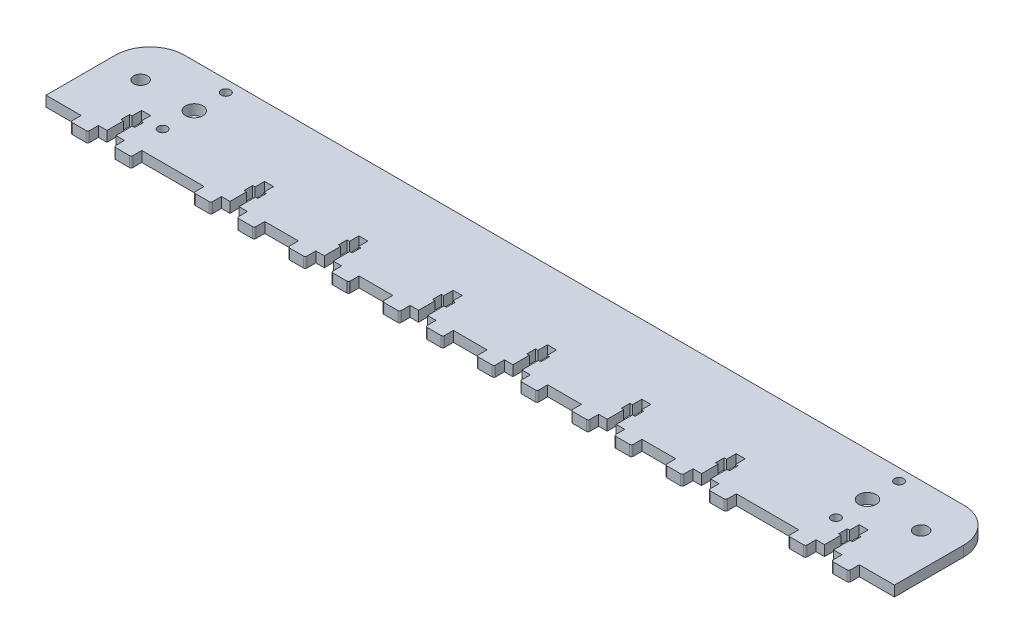
from build123d import *

# Parameters (mm, degrees)
SKETCH2_W                  = 490
SKETCH2_H                  = 60
BOSS_EXTRUDE1_DEPTH        = 6
F_10_0_10_DIAMETER_HOLE1_D = 10
M5_CLEARANCE_HOLE1_D       = 5.3
F_8_0_8_DIAMETER_HOLE1_D   = 8
CUT_EXTRUDE2_DEPTH         = 4
CUT_EXTRUDE2_DEPTH_BACK    = 4
SKETCH234_W                = 6.1
SKETCH234_H                = 10
BOSS_EXTRUDE2_DEPTH        = 3
BOSS_EXTRUDE2_DEPTH_BACK   = 3
FILLET1_R                  = 1
CUT_EXTRUDE21_DEPTH        = 4
CUT_EXTRUDE21_DEPTH_BACK   = 4
SKETCH2341_W               = 6.1
SKETCH2341_H               = 10
BOSS_EXTRUDE21_DEPTH       = 3
BOSS_EXTRUDE21_DEPTH_BACK  = 3
FILLET11_R                 = 1
CUT_EXTRUDE22_DEPTH        = 4
CUT_EXTRUDE22_DEPTH_BACK   = 4
SKETCH2342_W               = 6.1
SKETCH2342_H               = 10
BOSS_EXTRUDE22_DEPTH       = 3
BOSS_EXTRUDE22_DEPTH_BACK  = 3
FILLET12_R                 = 1
CUT_EXTRUDE23_DEPTH        = 4
CUT_EXTRUDE23_DEPTH_BACK   = 4
SKETCH2343_W               = 6.1
SKETCH2343_H               = 10
BOSS_EXTRUDE23_DEPTH       = 3
BOSS_EXTRUDE23_DEPTH_BACK  = 3
FILLET13_R                 = 1
CUT_EXTRUDE24_DEPTH        = 4
CUT_EXTRUDE24_DEPTH_BACK   = 4
SKETCH2344_W               = 6.1
SKETCH2344_H               = 10
BOSS_EXTRUDE24_DEPTH       = 3
BOSS_EXTRUDE24_DEPTH_BACK  = 3
FILLET14_R                 = 1
CUT_EXTRUDE25_DEPTH        = 4
CUT_EXTRUDE25_DEPTH_BACK   = 4
SKETCH2345_W               = 6.1
SKETCH2345_H               = 10
BOSS_EXTRUDE25_DEPTH       = 3
BOSS_EXTRUDE25_DEPTH_BACK  = 3
FILLET15_R                 = 1
CUT_EXTRUDE26_DEPTH        = 4
CUT_EXTRUDE26_DEPTH_BACK   = 4
SKETCH2346_W               = 6.1
SKETCH2346_H               = 10
BOSS_EXTRUDE26_DEPTH       = 3
BOSS_EXTRUDE26_DEPTH_BACK  = 3
FILLET16_R                 = 1
CUT_EXTRUDE27_DEPTH        = 4
CUT_EXTRUDE27_DEPTH_BACK   = 4
SKETCH2347_W               = 6.1
SKETCH2347_H               = 10
BOSS_EXTRUDE27_DEPTH       = 3
BOSS_EXTRUDE27_DEPTH_BACK  = 3
FILLET17_R                 = 1
FILLET18_R                 = 20


with BuildPart() as part:
    # Sketch2 → Boss-Extrude1 (new body)
    with BuildSketch(Plane(origin=(0, 0, 0), x_dir=(1, 0, 0), z_dir=(0, 1, 0))):
        Rectangle(SKETCH2_W, SKETCH2_H)
    extrude(amount=BOSS_EXTRUDE1_DEPTH)

    # Ø10.0 (10) Diameter Hole1 (through all)
    with Locations(Plane(origin=(0, 6, 0), x_dir=(1, 0, 0), z_dir=(0, 1, 0))):
        with Locations((194.4, 5)):
            f_10_0_10_diameter_hole1 = Hole(F_10_0_10_DIAMETER_HOLE1_D / 2)

    # M5 Clearance Hole1 (through all)
    with Locations(Plane(origin=(0, 6, 0), x_dir=(1, 0, 0), z_dir=(0, 1, 0))):
        with Locations((194.4, -13.25), (194.4, 23.25)):
            m5_clearance_hole1 = Hole(M5_CLEARANCE_HOLE1_D / 2)

    # Ø8.0 (8) Diameter Hole1 (through all)
    with Locations(Plane(origin=(0, 6, 0), x_dir=(1, 0, 0), z_dir=(0, 1, 0))):
        with Locations((225.4, 5)):
            f_8_0_8_diameter_hole1 = Hole(F_8_0_8_DIAMETER_HOLE1_D / 2)

    # Mirror1: Ø10.0 (10) Diameter Hole1, M5 Clearance Hole1, Ø8.0 (8) Diameter Hole1 across plane
    add(f_10_0_10_diameter_hole1.mirror(Plane(origin=(0, 0, 0), x_dir=(0, 0, 1), z_dir=(1, 0, 0))), mode=Mode.SUBTRACT)
    add(m5_clearance_hole1.mirror(Plane(origin=(0, 0, 0), x_dir=(0, 0, 1), z_dir=(1, 0, 0))), mode=Mode.SUBTRACT)
    add(f_8_0_8_diameter_hole1.mirror(Plane(origin=(0, 0, 0), x_dir=(0, 0, 1), z_dir=(1, 0, 0))), mode=Mode.SUBTRACT)

    # Sketch23 → Cut-Extrude2 (cut, two sides)
    with BuildSketch(Plane(origin=(187.2, 3, -20), x_dir=(0, 0, 1), z_dir=(0, 1, 0))) as cut_extrude2_sk:
        Polygon((30, 17.4), (30, 22.6), (35.5, 22.6), (35.5, 24), (40.5, 24), (40.5, 22.6), (50, 22.6), (50, 17.4), (40.5, 17.4), (40.5, 16), (35.5, 16), (35.5, 17.4), align=None)
    extrude(amount=CUT_EXTRUDE2_DEPTH, mode=Mode.SUBTRACT)
    extrude(cut_extrude2_sk.sketch, amount=-CUT_EXTRUDE2_DEPTH_BACK, mode=Mode.SUBTRACT)

    # Sketch234 → Boss-Extrude2 (add, two sides)
    with BuildSketch(Plane(origin=(187.2, 3, -20), x_dir=(0, 0, 1), z_dir=(0, 1, 0))) as boss_extrude2_sk:
        with Locations((53.05, 32.5)):
            Rectangle(SKETCH234_W, SKETCH234_H)
        with Locations((53.05, 7.5)):
            Rectangle(SKETCH234_W, SKETCH234_H)
    extrude(amount=BOSS_EXTRUDE2_DEPTH)
    extrude(boss_extrude2_sk.sketch, amount=-BOSS_EXTRUDE2_DEPTH_BACK)

    # Fillet1
    fillet1_edges = [part.edges().sort_by_distance(p)[0] for p in [
        (199.7, 3, 36.1),
        (189.7, 3, 36.1),
        (224.7, 3, 36.1),
        (214.7, 3, 36.1),
    ]]
    fillet(fillet1_edges, radius=FILLET1_R)

    # Sketch236 → Cut-Extrude21 (cut, two sides)
    with BuildSketch(Plane(origin=(116.166666667, 3, -20), x_dir=(0, 0, 1), z_dir=(0, 1, 0))) as cut_extrude21_sk:
        Polygon((30, 17.4), (30, 22.6), (35.5, 22.6), (35.5, 24), (40.5, 24), (40.5, 22.6), (50, 22.6), (50, 17.4), (40.5, 17.4), (40.5, 16), (35.5, 16), (35.5, 17.4), align=None)
    extrude(amount=CUT_EXTRUDE21_DEPTH, mode=Mode.SUBTRACT)
    extrude(cut_extrude21_sk.sketch, amount=-CUT_EXTRUDE21_DEPTH_BACK, mode=Mode.SUBTRACT)

    # Sketch2341 → Boss-Extrude21 (add, two sides)
    with BuildSketch(Plane(origin=(116.166666667, 3, -20), x_dir=(0, 0, 1), z_dir=(0, 1, 0))) as boss_extrude21_sk:
        with Locations((53.05, 32.5)):
            Rectangle(SKETCH2341_W, SKETCH2341_H)
        with Locations((53.05, 7.5)):
            Rectangle(SKETCH2341_W, SKETCH2341_H)
    extrude(amount=BOSS_EXTRUDE21_DEPTH)
    extrude(boss_extrude21_sk.sketch, amount=-BOSS_EXTRUDE21_DEPTH_BACK)

    # Fillet11
    fillet11_edges = [part.edges().sort_by_distance(p)[0] for p in [
        (153.666666667, 3, 36.1),
        (143.666666667, 3, 36.1),
        (128.666666667, 3, 36.1),
        (118.666666667, 3, 36.1),
    ]]
    fillet(fillet11_edges, radius=FILLET11_R)

    # Sketch237 → Cut-Extrude22 (cut, two sides)
    with BuildSketch(Plane(origin=(61.7, 3, -20), x_dir=(0, 0, 1), z_dir=(0, 1, 0))) as cut_extrude22_sk:
        Polygon((30, 17.4), (30, 22.6), (35.5, 22.6), (35.5, 24), (40.5, 24), (40.5, 22.6), (50, 22.6), (50, 17.4), (40.5, 17.4), (40.5, 16), (35.5, 16), (35.5, 17.4), align=None)
    extrude(amount=CUT_EXTRUDE22_DEPTH, mode=Mode.SUBTRACT)
    extrude(cut_extrude22_sk.sketch, amount=-CUT_EXTRUDE22_DEPTH_BACK, mode=Mode.SUBTRACT)

    # Sketch2342 → Boss-Extrude22 (add, two sides)
    with BuildSketch(Plane(origin=(61.7, 3, -20), x_dir=(0, 0, 1), z_dir=(0, 1, 0))) as boss_extrude22_sk:
        with Locations((53.05, 32.5)):
            Rectangle(SKETCH2342_W, SKETCH2342_H)
        with Locations((53.05, 7.5)):
            Rectangle(SKETCH2342_W, SKETCH2342_H)
    extrude(amount=BOSS_EXTRUDE22_DEPTH)
    extrude(boss_extrude22_sk.sketch, amount=-BOSS_EXTRUDE22_DEPTH_BACK)

    # Fillet12
    fillet12_edges = [part.edges().sort_by_distance(p)[0] for p in [
        (99.2, 3, 36.1),
        (89.2, 3, 36.1),
        (74.2, 3, 36.1),
        (64.2, 3, 36.1),
    ]]
    fillet(fillet12_edges, radius=FILLET12_R)

    # Sketch238 → Cut-Extrude23 (cut, two sides)
    with BuildSketch(Plane(origin=(7.233333333, 3, -20), x_dir=(0, 0, 1), z_dir=(0, 1, 0))) as cut_extrude23_sk:
        Polygon((30, 17.4), (30, 22.6), (35.5, 22.6), (35.5, 24), (40.5, 24), (40.5, 22.6), (50, 22.6), (50, 17.4), (40.5, 17.4), (40.5, 16), (35.5, 16), (35.5, 17.4), align=None)
    extrude(amount=CUT_EXTRUDE23_DEPTH, mode=Mode.SUBTRACT)
    extrude(cut_extrude23_sk.sketch, amount=-CUT_EXTRUDE23_DEPTH_BACK, mode=Mode.SUBTRACT)

    # Sketch2343 → Boss-Extrude23 (add, two sides)
    with BuildSketch(Plane(origin=(7.233333333, 3, -20), x_dir=(0, 0, 1), z_dir=(0, 1, 0))) as boss_extrude23_sk:
        with Locations((53.05, 32.5)):
            Rectangle(SKETCH2343_W, SKETCH2343_H)
        with Locations((53.05, 7.5)):
            Rectangle(SKETCH2343_W, SKETCH2343_H)
    extrude(amount=BOSS_EXTRUDE23_DEPTH)
    extrude(boss_extrude23_sk.sketch, amount=-BOSS_EXTRUDE23_DEPTH_BACK)

    # Fillet13
    fillet13_edges = [part.edges().sort_by_distance(p)[0] for p in [
        (44.733333333, 3, 36.1),
        (34.733333333, 3, 36.1),
        (19.733333333, 3, 36.1),
        (9.733333333, 3, 36.1),
    ]]
    fillet(fillet13_edges, radius=FILLET13_R)

    # Sketch239 → Cut-Extrude24 (cut, two sides)
    with BuildSketch(Plane(origin=(-47.233333333, 3, -20), x_dir=(0, 0, 1), z_dir=(0, 1, 0))) as cut_extrude24_sk:
        Polygon((30, 17.4), (30, 22.6), (35.5, 22.6), (35.5, 24), (40.5, 24), (40.5, 22.6), (50, 22.6), (50, 17.4), (40.5, 17.4), (40.5, 16), (35.5, 16), (35.5, 17.4), align=None)
    extrude(amount=CUT_EXTRUDE24_DEPTH, mode=Mode.SUBTRACT)
    extrude(cut_extrude24_sk.sketch, amount=-CUT_EXTRUDE24_DEPTH_BACK, mode=Mode.SUBTRACT)

    # Sketch2344 → Boss-Extrude24 (add, two sides)
    with BuildSketch(Plane(origin=(-47.233333333, 3, -20), x_dir=(0, 0, 1), z_dir=(0, 1, 0))) as boss_extrude24_sk:
        with Locations((53.05, 32.5)):
            Rectangle(SKETCH2344_W, SKETCH2344_H)
        with Locations((53.05, 7.5)):
            Rectangle(SKETCH2344_W, SKETCH2344_H)
    extrude(amount=BOSS_EXTRUDE24_DEPTH)
    extrude(boss_extrude24_sk.sketch, amount=-BOSS_EXTRUDE24_DEPTH_BACK)

    # Fillet14
    fillet14_edges = [part.edges().sort_by_distance(p)[0] for p in [
        (-9.733333333, 3, 36.1),
        (-19.733333333, 3, 36.1),
        (-34.733333333, 3, 36.1),
        (-44.733333333, 3, 36.1),
    ]]
    fillet(fillet14_edges, radius=FILLET14_R)

    # Sketch2310 → Cut-Extrude25 (cut, two sides)
    with BuildSketch(Plane(origin=(-101.7, 3, -20), x_dir=(0, 0, 1), z_dir=(0, 1, 0))) as cut_extrude25_sk:
        Polygon((30, 17.4), (30, 22.6), (35.5, 22.6), (35.5, 24), (40.5, 24), (40.5, 22.6), (50, 22.6), (50, 17.4), (40.5, 17.4), (40.5, 16), (35.5, 16), (35.5, 17.4), align=None)
    extrude(amount=CUT_EXTRUDE25_DEPTH, mode=Mode.SUBTRACT)
    extrude(cut_extrude25_sk.sketch, amount=-CUT_EXTRUDE25_DEPTH_BACK, mode=Mode.SUBTRACT)

    # Sketch2345 → Boss-Extrude25 (add, two sides)
    with BuildSketch(Plane(origin=(-101.7, 3, -20), x_dir=(0, 0, 1), z_dir=(0, 1, 0))) as boss_extrude25_sk:
        with Locations((53.05, 32.5)):
            Rectangle(SKETCH2345_W, SKETCH2345_H)
        with Locations((53.05, 7.5)):
            Rectangle(SKETCH2345_W, SKETCH2345_H)
    extrude(amount=BOSS_EXTRUDE25_DEPTH)
    extrude(boss_extrude25_sk.sketch, amount=-BOSS_EXTRUDE25_DEPTH_BACK)

    # Fillet15
    fillet15_edges = [part.edges().sort_by_distance(p)[0] for p in [
        (-64.2, 3, 36.1),
        (-74.2, 3, 36.1),
        (-89.2, 3, 36.1),
        (-99.2, 3, 36.1),
    ]]
    fillet(fillet15_edges, radius=FILLET15_R)

    # Sketch2311 → Cut-Extrude26 (cut, two sides)
    with BuildSketch(Plane(origin=(-156.166666667, 3, -20), x_dir=(0, 0, 1), z_dir=(0, 1, 0))) as cut_extrude26_sk:
        Polygon((30, 17.4), (30, 22.6), (35.5, 22.6), (35.5, 24), (40.5, 24), (40.5, 22.6), (50, 22.6), (50, 17.4), (40.5, 17.4), (40.5, 16), (35.5, 16), (35.5, 17.4), align=None)
    extrude(amount=CUT_EXTRUDE26_DEPTH, mode=Mode.SUBTRACT)
    extrude(cut_extrude26_sk.sketch, amount=-CUT_EXTRUDE26_DEPTH_BACK, mode=Mode.SUBTRACT)

    # Sketch2346 → Boss-Extrude26 (add, two sides)
    with BuildSketch(Plane(origin=(-156.166666667, 3, -20), x_dir=(0, 0, 1), z_dir=(0, 1, 0))) as boss_extrude26_sk:
        with Locations((53.05, 32.5)):
            Rectangle(SKETCH2346_W, SKETCH2346_H)
        with Locations((53.05, 7.5)):
            Rectangle(SKETCH2346_W, SKETCH2346_H)
    extrude(amount=BOSS_EXTRUDE26_DEPTH)
    extrude(boss_extrude26_sk.sketch, amount=-BOSS_EXTRUDE26_DEPTH_BACK)

    # Fillet16
    fillet16_edges = [part.edges().sort_by_distance(p)[0] for p in [
        (-118.666666667, 3, 36.1),
        (-128.666666667, 3, 36.1),
        (-143.666666667, 3, 36.1),
        (-153.666666667, 3, 36.1),
    ]]
    fillet(fillet16_edges, radius=FILLET16_R)

    # Sketch2312 → Cut-Extrude27 (cut, two sides)
    with BuildSketch(Plane(origin=(-227.2, 3, -20), x_dir=(0, 0, 1), z_dir=(0, 1, 0))) as cut_extrude27_sk:
        Polygon((30, 17.4), (30, 22.6), (35.5, 22.6), (35.5, 24), (40.5, 24), (40.5, 22.6), (50, 22.6), (50, 17.4), (40.5, 17.4), (40.5, 16), (35.5, 16), (35.5, 17.4), align=None)
    extrude(amount=CUT_EXTRUDE27_DEPTH, mode=Mode.SUBTRACT)
    extrude(cut_extrude27_sk.sketch, amount=-CUT_EXTRUDE27_DEPTH_BACK, mode=Mode.SUBTRACT)

    # Sketch2347 → Boss-Extrude27 (add, two sides)
    with BuildSketch(Plane(origin=(-227.2, 3, -20), x_dir=(0, 0, 1), z_dir=(0, 1, 0))) as boss_extrude27_sk:
        with Locations((53.05, 32.5)):
            Rectangle(SKETCH2347_W, SKETCH2347_H)
        with Locations((53.05, 7.5)):
            Rectangle(SKETCH2347_W, SKETCH2347_H)
    extrude(amount=BOSS_EXTRUDE27_DEPTH)
    extrude(boss_extrude27_sk.sketch, amount=-BOSS_EXTRUDE27_DEPTH_BACK)

    # Fillet17
    fillet17_edges = [part.edges().sort_by_distance(p)[0] for p in [
        (-189.7, 3, 36.1),
        (-199.7, 3, 36.1),
        (-214.7, 3, 36.1),
        (-224.7, 3, 36.1),
    ]]
    fillet(fillet17_edges, radius=FILLET17_R)

    # Fillet18
    fillet18_edges = [part.edges().sort_by_distance(p)[0] for p in [
        (-245, 3, -30),
        (245, 3, -30),
    ]]
    fillet(fillet18_edges, radius=FILLET18_R)


solid = part.part
